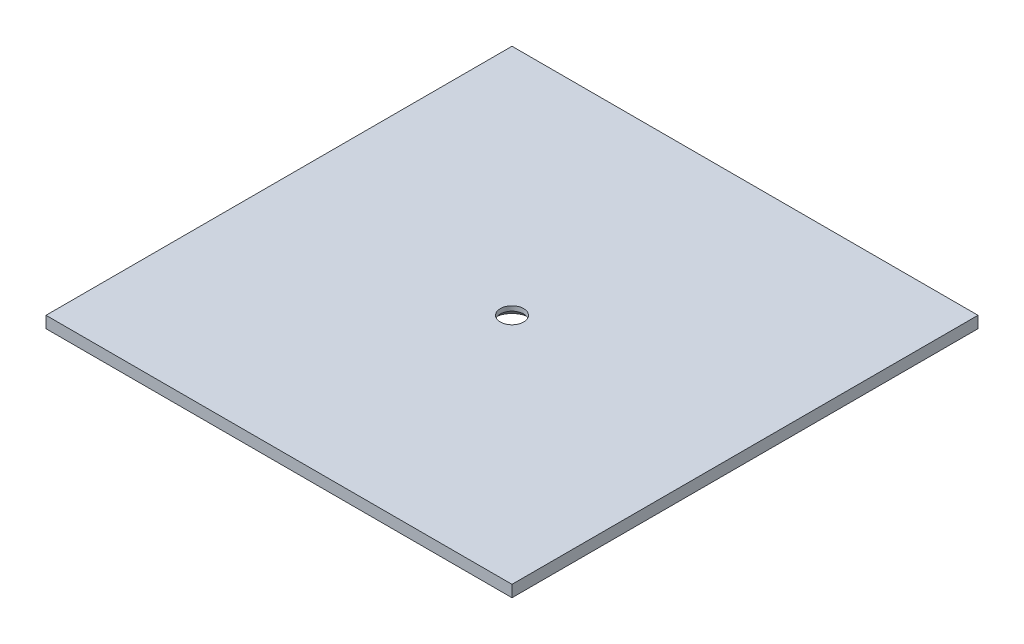
from build123d import *

# Parameters (mm, degrees)
SKETCH_1_W      = 200
SKETCH_1_H      = 200
SKETCH_1_R      = 5
EXTRUDE_1_DEPTH = 5
CHAMFER_1_SIZE  = 3


with BuildPart() as part:
    # Эскиз1 → Бобышка-Вытянуть1 (new body)
    with BuildSketch(Plane(origin=(0, 0, 0), x_dir=(1, 0, 0), z_dir=(0, 1, 0))):
        Rectangle(SKETCH_1_W, SKETCH_1_H)
        Circle(SKETCH_1_R, mode=Mode.SUBTRACT)
    extrude(amount=EXTRUDE_1_DEPTH)

    # Фаска1
    chamfer_1_edges = [part.edges().sort_by_distance(p)[0] for p in [
        (-5, 0, 0),
    ]]
    chamfer(chamfer_1_edges, length=CHAMFER_1_SIZE)


solid = part.part
